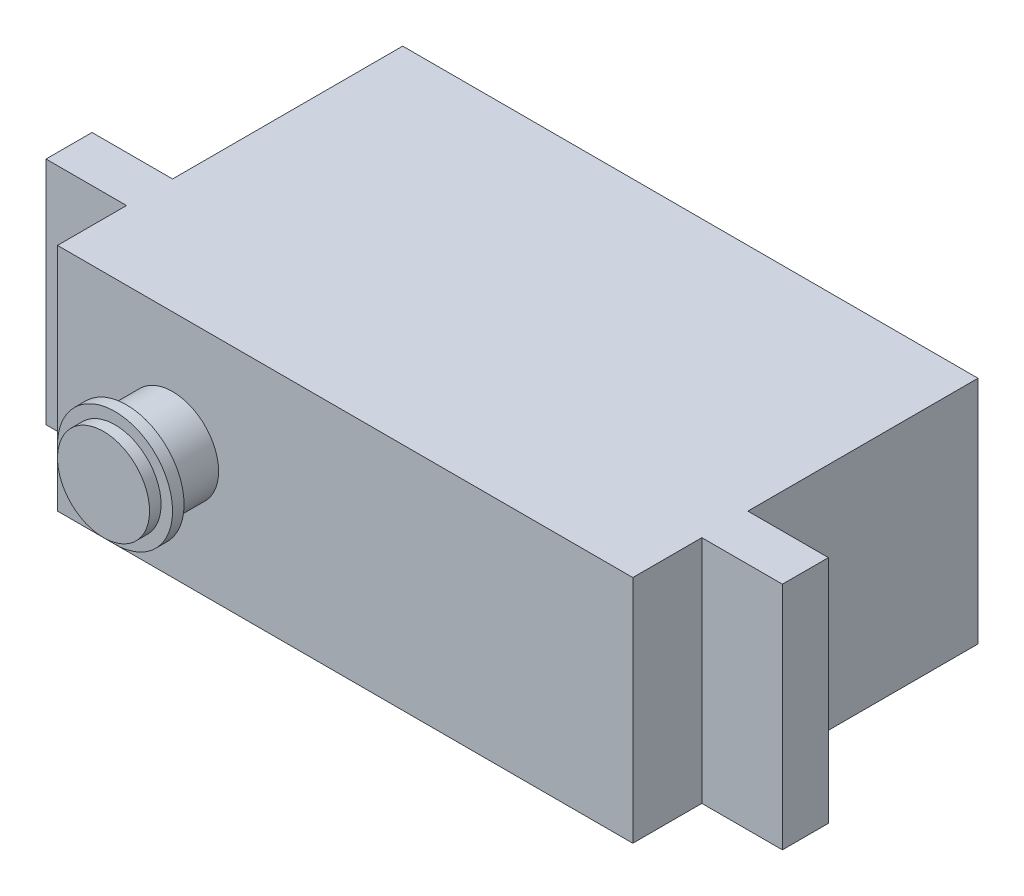
from build123d import *

# Parameters (mm, degrees)
SKETCH_1_W      = 25
SKETCH_1_H      = 10
EXTRUDE_1_DEPTH = 15
SKETCH_2_R      = 2
EXTRUDE_2_DEPTH = 3
SKETCH_3_W      = 2
SKETCH_3_H      = 10
EXTRUDE_3_DEPTH = 3.5
SKETCH_4_W      = 2
SKETCH_4_H      = 10
EXTRUDE_4_DEPTH = 3.5
EXTRUDE_START   = 2
SKETCH_7_R      = 2.5
EXTRUDE_5_DEPTH = 0.5


with BuildPart() as part:
    # 스케치1 → 보스-돌출1 (new body)
    with BuildSketch(Plane.XY):
        Rectangle(SKETCH_1_W, SKETCH_1_H)
    extrude(amount=EXTRUDE_1_DEPTH)

    # 스케치2 → 보스-돌출2 (add)
    with BuildSketch(Plane.XY.offset(15)):
        with Locations((-7.5, 0)):
            Circle(SKETCH_2_R)
    extrude(amount=EXTRUDE_2_DEPTH)

    # 스케치3 → 보스-돌출3 (add)
    with BuildSketch(Plane(origin=(12.5, 0, 0), x_dir=(0, 0, -1), z_dir=(1, 0, 0))):
        with Locations((-11, 0)):
            Rectangle(SKETCH_3_W, SKETCH_3_H)
    extrude(amount=EXTRUDE_3_DEPTH)

    # 스케치4 → 보스-돌출4 (add)
    with BuildSketch(Plane.ZY.offset(12.5)):
        with Locations((11, 0)):
            Rectangle(SKETCH_4_W, SKETCH_4_H)
    extrude(amount=EXTRUDE_4_DEPTH)

    # 스케치7 → 보스-돌출5 (add)
    with BuildSketch(Plane.XY.offset(15).offset(EXTRUDE_START)):
        with Locations((-7.5, 0)):
            Circle(SKETCH_7_R)
    extrude(amount=EXTRUDE_5_DEPTH)


solid = part.part
